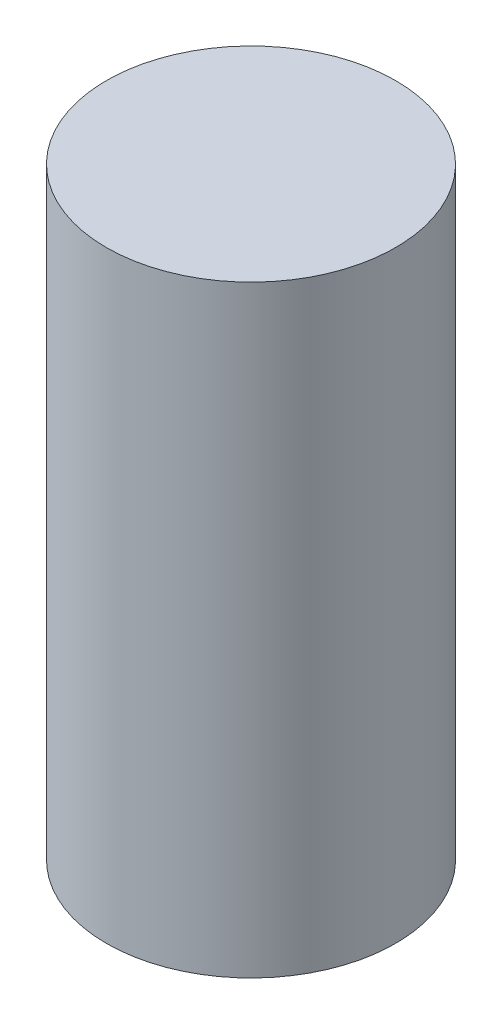
from build123d import *

# Parameters (mm, degrees)
SKETCH1_R           = 6
BOSS_EXTRUDE1_DEPTH = 25


with BuildPart() as part:
    # Sketch1 → Boss-Extrude1 (new body)
    with BuildSketch(Plane(origin=(0, 0, 0), x_dir=(1, 0, 0), z_dir=(0, 1, 0))):
        Circle(SKETCH1_R)
    extrude(amount=BOSS_EXTRUDE1_DEPTH)


solid = part.part
